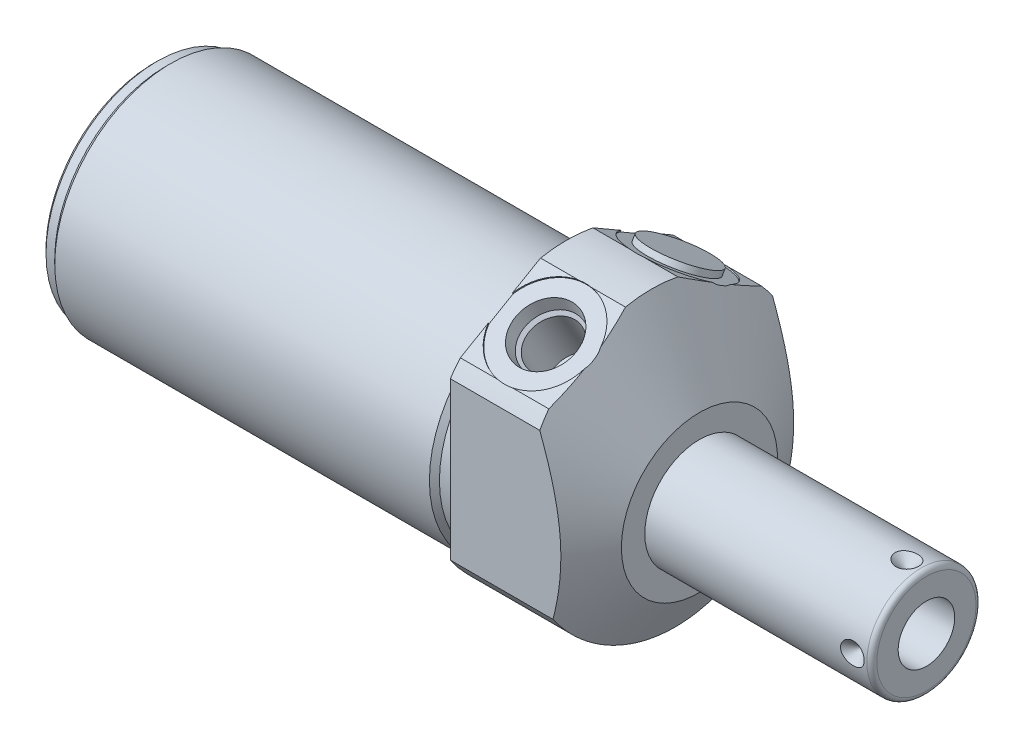
from build123d import *

# Parameters (mm, degrees)
SKETCH1_R           = 28.575
EXTRUDE1_DEPTH      = 27.0002
EXTRUDE1_DEPTH_BACK = 84.1248
CUT_EXTRUDE1_REACH  = 86.125
SKETCH2_R           = 28.575
SKETCH2_R_2         = 23.622
CUT_EXTRUDE3_START  = -27.0002
CUT_EXTRUDE3_DEPTH  = 27.0002
SKETCH18_R          = 9.525
CUT_EXTRUDE4_DEPTH  = 0.254
SKETCH19_R          = 9.525
CUT_EXTRUDE5_DEPTH  = 0.254
CHAMFER1_SIZE       = 0.762
SKETCH15_R          = 6.9469
EXTRUDE2_DEPTH      = 1.27
CIRPATTERN1_COUNT   = 4


with BuildPart() as part:
    # Sketch1 → Extrude1 (new body, two sides)
    with BuildSketch(Plane(origin=(0, 0, 0), x_dir=(0, 0, -1), z_dir=(1, 0, 0))) as extrude1_sk:
        Circle(SKETCH1_R)
    extrude(amount=EXTRUDE1_DEPTH)
    extrude(extrude1_sk.sketch, amount=-EXTRUDE1_DEPTH_BACK)

    # Sketch2 → Cut-Extrude1 (cut, up to next)
    with BuildSketch(Plane(origin=(0, 0, 0), x_dir=(0, 0, -1), z_dir=(1, 0, 0)), mode=Mode.PRIVATE) as cut_extrude1_sk1:
        Circle(SKETCH2_R)
        with Locations((0, -4.191)):
            Circle(SKETCH2_R_2, mode=Mode.SUBTRACT)
    cut_extrude1_tool1 = extrude(cut_extrude1_sk1.sketch, amount=-CUT_EXTRUDE1_REACH, mode=Mode.PRIVATE) & part.part
    add(cut_extrude1_tool1.solids().sort_by_distance((0, 0, 27.766777))[0], mode=Mode.SUBTRACT)

    # Sketch4 → Cut-Extrude3 (cut)
    with BuildSketch(Plane.ZY.offset(CUT_EXTRUDE3_START)):
        with BuildLine():
            Line((23.6855, -25.666178421), (23.6855, 17.476089577))
            Line((23.6855, 17.476089577), (0, 31.150919378))
            Line((0, 31.150919378), (-23.6855, 17.476089577))
            Line((-23.6855, 17.476089577), (-23.6855, -25.666178421))
            ThreePointArc((-23.6855, -25.666178421), (0, 34.925), (23.6855, -25.666178421))
        make_face()
    extrude(amount=CUT_EXTRUDE3_DEPTH, mode=Mode.SUBTRACT)

    # Sketch6 → Cut-Revolve2 (revolve, cut)
    with BuildSketch(Plane.XY, mode=Mode.PRIVATE) as cut_revolve2_sk:
        Polygon((0.750392661, 57.15), (27.0002, 11.684), (27.0002, 57.15), align=None)
    revolve(cut_revolve2_sk.sketch.rotate(Axis((-0.562097706, -4.191, 0), (1, 0, 0)), 270), axis=Axis((-0.562097706, -4.191, 0), (1, 0, 0)), mode=Mode.SUBTRACT)  # turned: the seam where the file's is

    # S2D0002 → Cut-Revolve3 (revolve, cut)
    with BuildSketch(Plane(origin=(9.0932, 23.136869081, 13.372742289), x_dir=(0, 0.5, -0.866025404), z_dir=(1, 0, 0))):
        Polygon((0, 0), (6.1849, 0), (5.642306865, -2.5527), (4.9784, -3.216606865), (4.9784, -13.462), (0, -13.462), align=None)
    revolve(axis=Axis((9.0932, 10.895513396, 6.305192289), (0, 0.866025404, 0.5)), mode=Mode.SUBTRACT)

    # Sketch8 → Cut-Revolve4 (revolve, cut)
    with BuildSketch(Plane(origin=(9.0932, 23.136869081, -13.372742289), x_dir=(0, -0.5, -0.866025404), z_dir=(1, 0, 0))):
        Polygon((0, 0), (6.1849, 0), (5.642306865, -2.5527), (4.9784, -3.216606865), (4.9784, -13.462), (0, -13.462), align=None)
    revolve(axis=Axis((9.0932, 10.895513396, -6.305192289), (0, 0.866025404, -0.5)), mode=Mode.SUBTRACT)

    # Sketch18 → Cut-Extrude4 (cut)
    with BuildSketch(Plane(origin=(0, 23.363189534, 13.488743766), x_dir=(1, 0, 0), z_dir=(0, 0.866025404, 0.5))):
        with Locations((9.0932, -0.0127)):
            Circle(SKETCH18_R)
    extrude(amount=-CUT_EXTRUDE4_DEPTH, mode=Mode.SUBTRACT)

    # Sketch19 → Cut-Extrude5 (cut)
    with BuildSketch(Plane(origin=(0, 23.363189534, -13.488743766), x_dir=(1, 0, 0), z_dir=(0, 0.866025404, -0.5))):
        with Locations((9.0932, 0.0127)):
            Circle(SKETCH19_R)
    extrude(amount=-CUT_EXTRUDE5_DEPTH, mode=Mode.SUBTRACT)

    # Sketch10 → Cut-Revolve6 (revolve, cut)
    with BuildSketch(Plane.XY, mode=Mode.PRIVATE) as cut_revolve6_sk:
        Polygon((0, 19.431), (0, 18.415), (-3.302, 18.415), (-4.318, 19.431), align=None)
    revolve(cut_revolve6_sk.sketch.rotate(Axis((-4.5339, -4.191, 0), (1, 0, 0)), 90), axis=Axis((-4.5339, -4.191, 0), (1, 0, 0)), mode=Mode.SUBTRACT)  # turned: the seam where the file's is

    # Sketch12 → Cut-Revolve8 (revolve, cut)
    with BuildSketch(Plane.XY, mode=Mode.PRIVATE) as cut_revolve8_sk:
        Polygon((-84.1248, 19.431), (-84.1248, 18.415), (-81.5848, 18.415), (-80.5688, 19.431), align=None)
    revolve(cut_revolve8_sk.sketch.rotate(Axis((-84.3026, -4.191, 0), (1, 0, 0)), 90), axis=Axis((-84.3026, -4.191, 0), (1, 0, 0)), mode=Mode.SUBTRACT)  # turned: the seam where the file's is

    # Chamfer1
    chamfer1_edges = [part.edges().sort_by_distance(p)[0] for p in [
        (-84.1248, -4.191, -22.606),
    ]]
    chamfer(chamfer1_edges, length=CHAMFER1_SIZE)

    # Sketch13 → Revolve1 (revolve)
    with BuildSketch(Plane(origin=(0, 0, 0), x_dir=(0, -1, 0), z_dir=(0, 0, 1)), mode=Mode.PRIVATE) as revolve1_sk:
        with BuildLine():
            Line((4.191, 27.0002), (4.191, 73.2028))
            Line((4.191, 73.2028), (14.2875, 73.2028))
            ThreePointArc((14.2875, 73.2028), (15.00592049, 72.90522049), (15.3035, 72.1868))
            Line((15.3035, 72.1868), (15.3035, 27.0002))
            Line((15.3035, 27.0002), (4.191, 27.0002))
        make_face()
    revolve(revolve1_sk.sketch.rotate(Axis((25.10663, -4.191, 0), (1, 0, 0)), 270), axis=Axis((25.10663, -4.191, 0), (1, 0, 0)))  # turned: the seam where the file's is

    # S2D0001 → Cut-Revolve9 (revolve, cut)
    with BuildSketch(Plane(origin=(64.8716, -9.9441, 0), x_dir=(0, -1, 0), z_dir=(0, 0, 1)), mode=Mode.PRIVATE) as cut_revolve9_sk:
        Polygon((0, 8.3312), (0, -8.6868), (-5.7531, -12.143611227), (-5.7531, 8.3312), align=None)
    revolve(cut_revolve9_sk.sketch.rotate(Axis((43.373048211, -4.191, 0), (1, 0, 0)), 270), axis=Axis((43.373048211, -4.191, 0), (1, 0, 0)), mode=Mode.SUBTRACT)  # turned: the seam where the file's is

    # Sketch15 → Extrude2 (add)
    with BuildSketch(Plane(origin=(27.0002, 23.143219081, -13.361743766), x_dir=(0, -0.5, -0.866025404), z_dir=(0, -0.866025404, 0.5))):
        with Locations((0.0127, -17.907)):
            Circle(SKETCH15_R)
    extrude(amount=-EXTRUDE2_DEPTH)

    # Sketch16 → Cut-Revolve10 (revolve, cut)
    with BuildSketch(Plane(origin=(60.9092, 6.9215, 0), x_dir=(-1, 0, 0), z_dir=(0, 0, -1)), mode=Mode.PRIVATE) as cut_revolve10_sk:
        Polygon((-8.3312, 0), (-5.9182, 0), (-8.3312, -2.413), align=None)
    cut_revolve10 = revolve(cut_revolve10_sk.sketch.rotate(Axis((69.2404, 2.435048935, 0), (0, 1, 0)), 90), axis=Axis((69.2404, 2.435048935, 0), (0, 1, 0)), mode=Mode.SUBTRACT)  # turned: the seam where the file's is

    # CirPattern1: Cut-Revolve10 ×4 about axis
    cirpattern1_axis = Axis((25.10663, -4.191, 0), (-1, 0, 0))
    for i in range(1, CIRPATTERN1_COUNT):
        add(cut_revolve10.rotate(cirpattern1_axis, i * 360 / CIRPATTERN1_COUNT), mode=Mode.SUBTRACT)


solid = part.part
